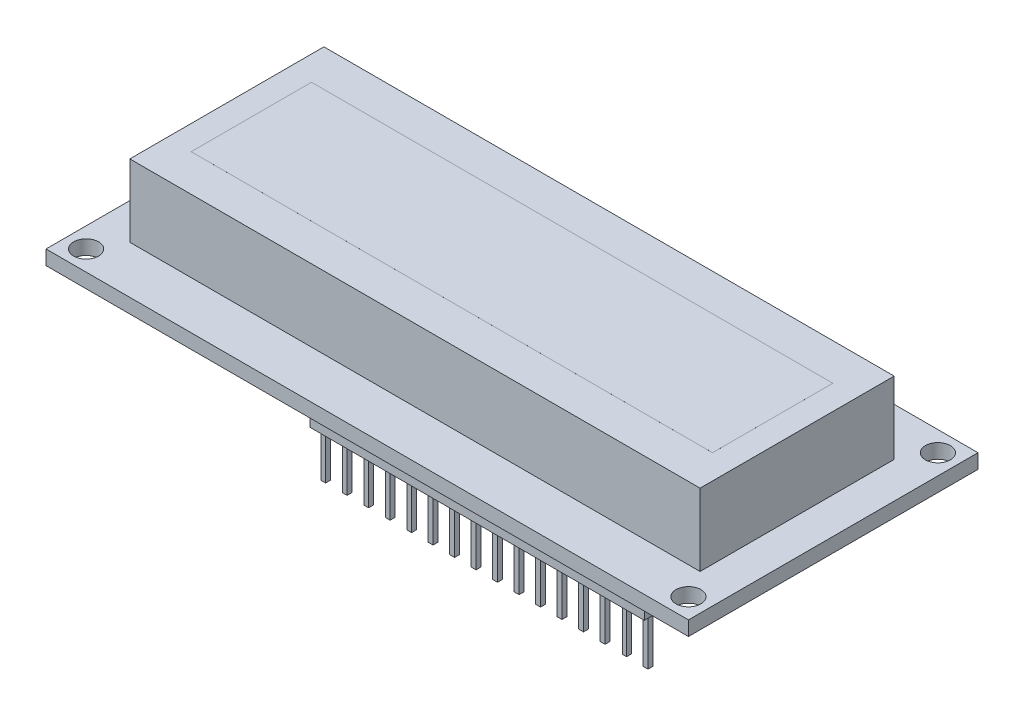
from build123d import *

# Parameters (mm, degrees)
SKETCH1_W                = 71.1
SKETCH1_H                = 24.2
BOSS_EXTRUDE1_DEPTH      = 6
SKETCH2_W                = 71.1
SKETCH2_H                = 24.2
SKETCH2_W_2              = 2.5
SKETCH2_H_2              = 18.2
BOSS_EXTRUDE2_DEPTH      = 3
SKETCH3_W                = 80.1
SKETCH3_H                = 36.1
SKETCH3_R                = 1.55
BOSS_EXTRUDE3_DEPTH      = 1.8
SKETCH4_W                = 65
SKETCH4_H                = 15
BOSS_EXTRUDE4_DEPTH      = 0.001
BOSS_EXTRUDE4_DEPTH_BACK = 6
SKETCH5_W                = 41.7
SKETCH5_H                = 2.5
BOSS_EXTRUDE5_DEPTH      = 2.5
SKETCH6_W                = 0.6
SKETCH6_H                = 0.6
SKETCH6_W_2              = 0.52
BOSS_EXTRUDE6_DEPTH      = 6


with BuildPart() as part:
    # Sketch1 → Boss-Extrude1 (new body)
    with BuildSketch(Plane(origin=(0, 0, 0), x_dir=(1, 0, 0), z_dir=(0, 1, 0))):
        Rectangle(SKETCH1_W, SKETCH1_H)
    extrude(amount=BOSS_EXTRUDE1_DEPTH)

    # Sketch2 → Boss-Extrude2 (add)
    with BuildSketch(Plane.XZ):
        Rectangle(SKETCH2_W, SKETCH2_H)
        with Locations((-36.8, 0)):
            Rectangle(SKETCH2_W_2, SKETCH2_H_2)
    extrude(amount=BOSS_EXTRUDE2_DEPTH)

    # Sketch3 → Boss-Extrude3 (add)
    with BuildSketch(Plane.XZ.offset(3)):
        Rectangle(SKETCH3_W, SKETCH3_H)
        with Locations((-37.55, -15.55)):
            Circle(SKETCH3_R, mode=Mode.SUBTRACT)
        with Locations((37.55, -15.55)):
            Circle(SKETCH3_R, mode=Mode.SUBTRACT)
        with Locations((37.55, 15.55)):
            Circle(SKETCH3_R, mode=Mode.SUBTRACT)
        with Locations((-37.55, 15.55)):
            Circle(SKETCH3_R, mode=Mode.SUBTRACT)
    extrude(amount=BOSS_EXTRUDE3_DEPTH)

    # Sketch4 → Boss-Extrude4 (add, two sides)
    with BuildSketch(Plane(origin=(0, 6, 0), x_dir=(1, 0, 0), z_dir=(0, 1, 0))) as boss_extrude4_sk:
        Rectangle(SKETCH4_W, SKETCH4_H)
    extrude(amount=BOSS_EXTRUDE4_DEPTH)
    extrude(boss_extrude4_sk.sketch, amount=-BOSS_EXTRUDE4_DEPTH_BACK)

    # Sketch5 → Boss-Extrude5 (add)
    with BuildSketch(Plane.XZ.offset(4.8)):
        with Locations((12.2, 15.3)):
            Rectangle(SKETCH5_W, SKETCH5_H)
    extrude(amount=BOSS_EXTRUDE5_DEPTH)

    # Sketch6 → Boss-Extrude6 (add)
    with BuildSketch(Plane.XZ.offset(7.3)):
        with Locations((32.25, 15.292216916)):
            Rectangle(SKETCH6_W, SKETCH6_H)
        with Locations((29.61, 15.292216916)):
            Rectangle(SKETCH6_W_2, SKETCH6_H)
        with Locations((26.89, 15.292216916)):
            Rectangle(SKETCH6_W, SKETCH6_H)
        with Locations((24.21, 15.292216916)):
            Rectangle(SKETCH6_W, SKETCH6_H)
        with Locations((21.53, 15.292216916)):
            Rectangle(SKETCH6_W, SKETCH6_H)
        with Locations((18.85, 15.292216916)):
            Rectangle(SKETCH6_W, SKETCH6_H)
        with Locations((16.17, 15.292216916)):
            Rectangle(SKETCH6_W, SKETCH6_H)
        with Locations((13.49, 15.292216916)):
            Rectangle(SKETCH6_W, SKETCH6_H)
        with Locations((10.81, 15.292216916)):
            Rectangle(SKETCH6_W, SKETCH6_H)
        with Locations((8.13, 15.292216916)):
            Rectangle(SKETCH6_W, SKETCH6_H)
        with Locations((5.45, 15.292216916)):
            Rectangle(SKETCH6_W, SKETCH6_H)
        with Locations((2.77, 15.292216916)):
            Rectangle(SKETCH6_W, SKETCH6_H)
        with Locations((-7.95, 15.292216916)):
            Rectangle(SKETCH6_W, SKETCH6_H)
        with Locations((-5.27, 15.292216916)):
            Rectangle(SKETCH6_W, SKETCH6_H)
        with Locations((0.09, 15.292216916)):
            Rectangle(SKETCH6_W, SKETCH6_H)
        with Locations((-2.59, 15.292216916)):
            Rectangle(SKETCH6_W, SKETCH6_H)
    extrude(amount=BOSS_EXTRUDE6_DEPTH)


solid = part.part
